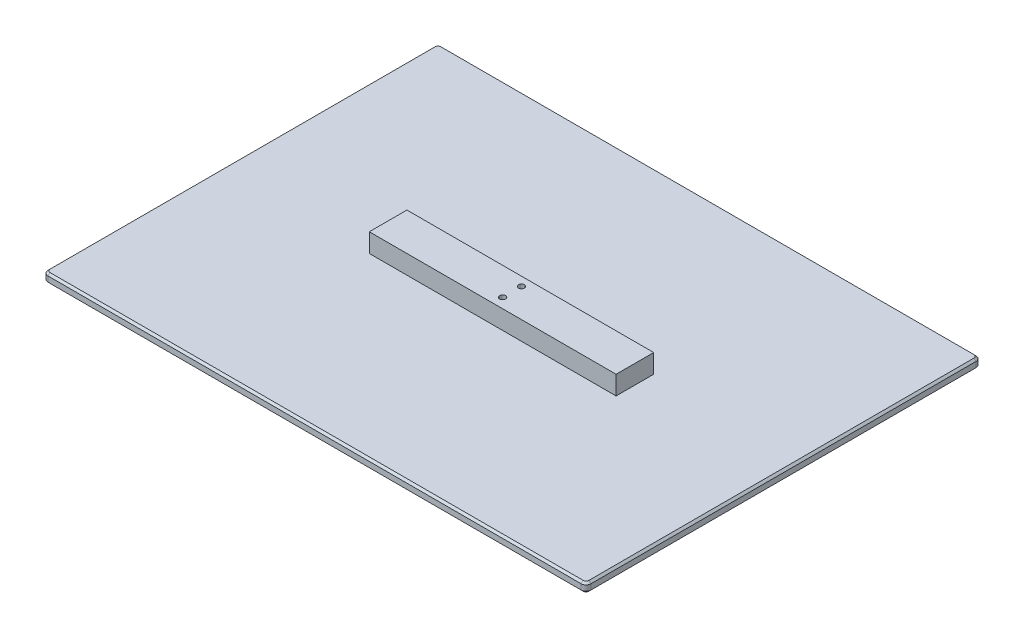
from build123d import *

# Parameters (mm, degrees)
SKETCH1_W           = 550
SKETCH1_H           = 400
BOSS_EXTRUDE1_DEPTH = 9.525
FILLET1_R           = 5
CHAMFER1_SIZE       = 2
CHAMFER2_SIZE       = 2
SKETCH4_W           = 250
SKETCH4_H           = 38.1
BOSS_EXTRUDE3_DEPTH = 19.05
SKETCH2_R           = 3
CUT_EXTRUDE1_DEPTH  = 20.05


with BuildPart() as part:
    # Sketch1 → Boss-Extrude1 (new body)
    with BuildSketch(Plane(origin=(0, 0, 0), x_dir=(1, 0, 0), z_dir=(0, 1, 0))):
        Rectangle(SKETCH1_W, SKETCH1_H)
    extrude(amount=BOSS_EXTRUDE1_DEPTH)

    # Fillet1
    fillet1_edges = [part.edges().sort_by_distance(p)[0] for p in [
        (275, 4.7625, 200),
        (-275, 4.7625, 200),
        (-275, 4.7625, -200),
        (275, 4.7625, -200),
    ]]
    fillet(fillet1_edges, radius=FILLET1_R)

    # Chamfer1
    chamfer1_edges = [part.edges().sort_by_distance(p)[0] for p in [
        (-275, 9.525, 0),
        (0, 9.525, -200),
        (275, 9.525, 0),
        (0, 9.525, 200),
        (-273.535533906, 9.525, 198.535533906),
        (273.535533906, 9.525, 198.535533906),
        (273.535533906, 9.525, -198.535533906),
        (-273.535533906, 9.525, -198.535533906),
    ]]
    chamfer(chamfer1_edges, length=CHAMFER1_SIZE)

    # Chamfer2
    chamfer2_edges = [part.edges().sort_by_distance(p)[0] for p in [
        (-275, 0, 0),
        (275, 0, 0),
        (0, 0, 200),
        (0, 0, -200),
        (-273.535533906, 0, 198.535533906),
        (273.535533906, 0, 198.535533906),
        (273.535533906, 0, -198.535533906),
        (-273.535533906, 0, -198.535533906),
    ]]
    chamfer(chamfer2_edges, length=CHAMFER2_SIZE)

    # Sketch4 → Boss-Extrude3 (add)
    with BuildSketch(Plane(origin=(0, 9.525, 0), x_dir=(1, 0, 0), z_dir=(0, 1, 0))):
        with Locations((0, -0.5)):
            Rectangle(SKETCH4_W, SKETCH4_H)
    extrude(amount=BOSS_EXTRUDE3_DEPTH)

    # Sketch2 → Cut-Extrude1 (cut, through all)
    with BuildSketch(Plane(origin=(0, 9.525, 0), x_dir=(1, 0, 0), z_dir=(0, 1, 0))):
        with Locations((0, 9.55)):
            Circle(SKETCH2_R)
        with Locations((0, -9.55)):
            Circle(SKETCH2_R)
    extrude(amount=CUT_EXTRUDE1_DEPTH, mode=Mode.SUBTRACT)


solid = part.part
